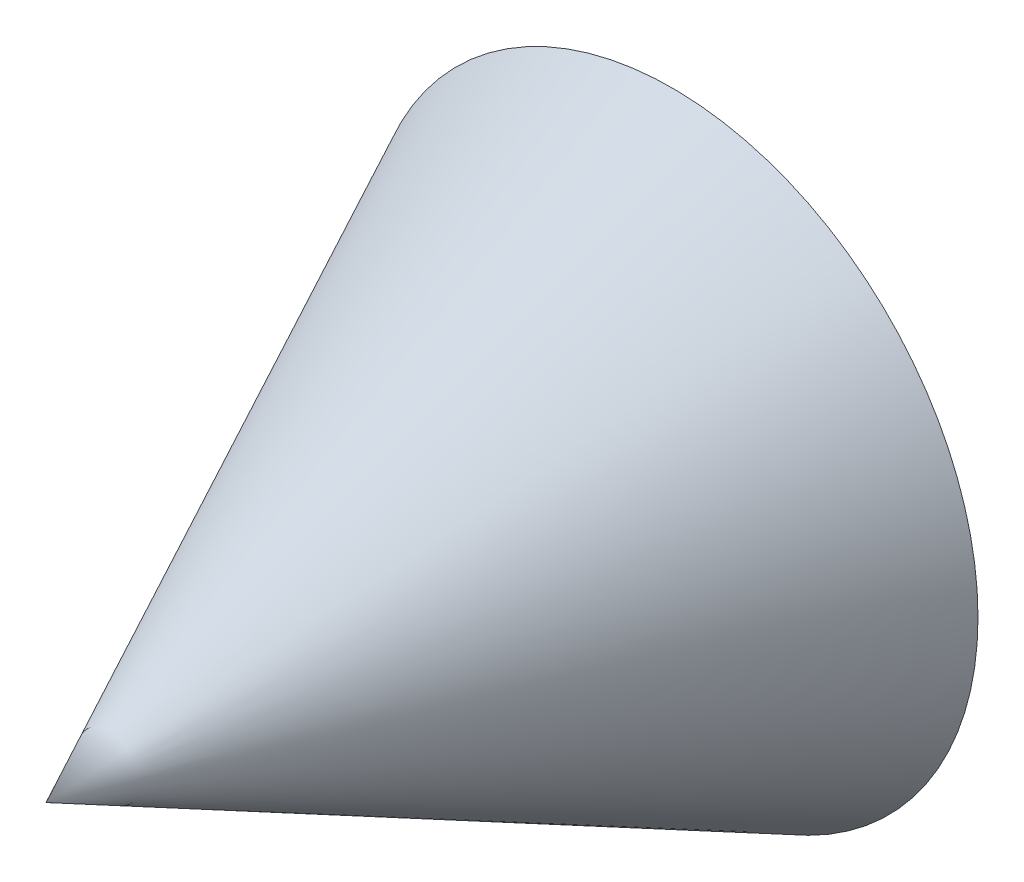
from build123d import *

# Parameters (mm, degrees)
ESQUISSE1_R        = 40
BOSS_EXTRU_1_DEPTH = 83
BOSS_EXTRU_1_TAPER = 26


with BuildPart() as part:
    # Esquisse1 → Boss.-Extru.1 (new body)
    with BuildSketch(Plane.XY):
        Circle(ESQUISSE1_R)
    extrude(amount=BOSS_EXTRU_1_DEPTH, taper=BOSS_EXTRU_1_TAPER)

    # Enlèv. mat.-Extru.1 cone 1 section (through the dimple's axis) → Enlèv. mat.-Extru.1 (revolve, cut)
    with BuildSketch(Plane.YZ):
        Polygon((0, 0), (30, 0), (0, 51.961524227), align=None)
    revolve(axis=Axis((0, 0, 0), (0, 0, 1)), mode=Mode.SUBTRACT)


solid = part.part
